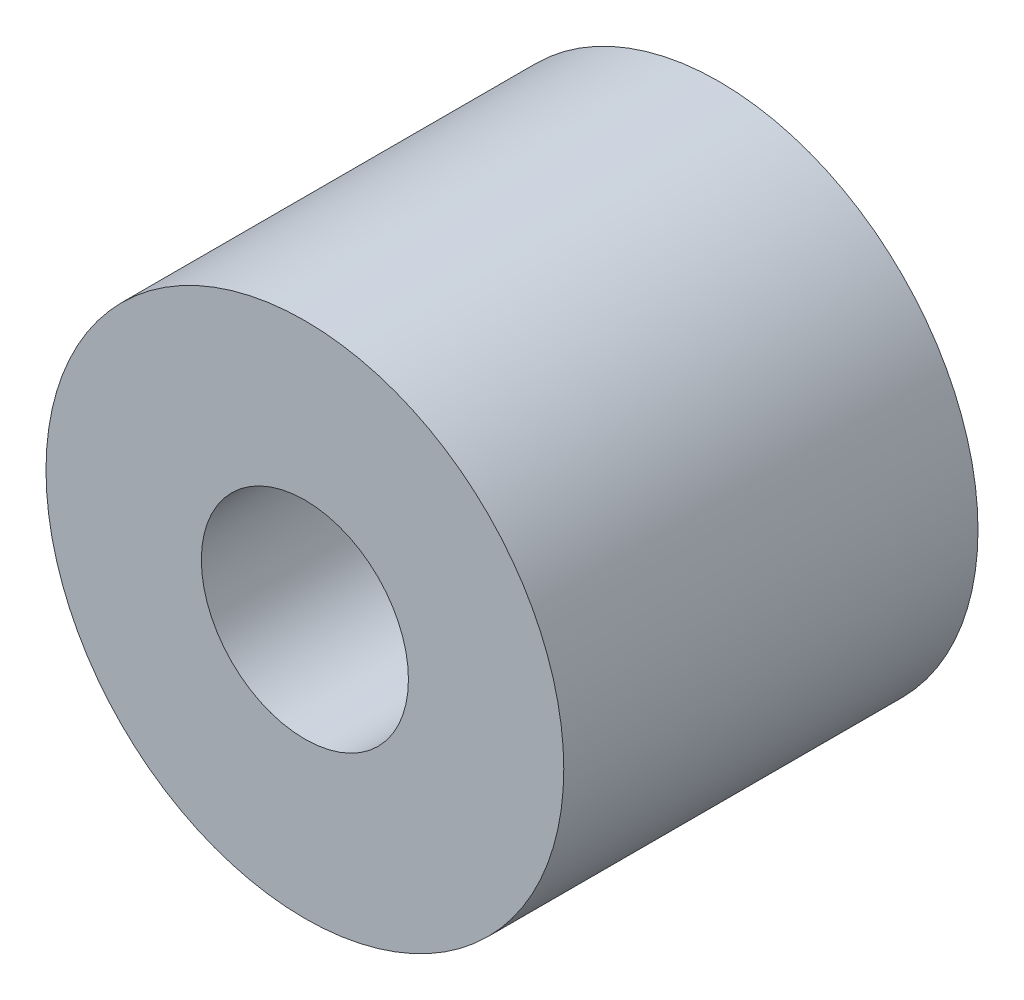
from build123d import *

# Parameters (mm, degrees)
SKETCH1_R           = 7.9375
SKETCH1_R_2         = 3.175
BOSS_EXTRUDE1_DEPTH = 12.7


with BuildPart() as part:
    # Sketch1 → Boss-Extrude1 (new body)
    with BuildSketch(Plane.XY):
        Circle(SKETCH1_R)
        Circle(SKETCH1_R_2, mode=Mode.SUBTRACT)
    extrude(amount=BOSS_EXTRUDE1_DEPTH)


solid = part.part
